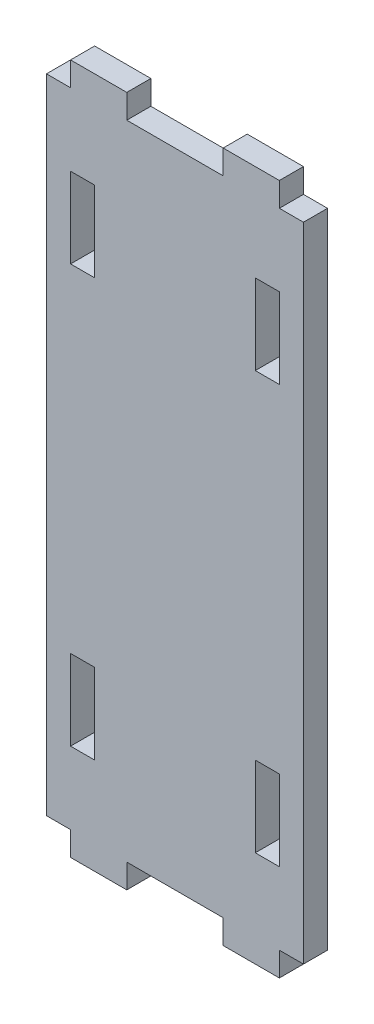
from build123d import *

# Parameters (mm, degrees)
SKETCH_1_W          = 32
SKETCH_1_H          = 86
EXTRUDE_1_DEPTH     = 3
SKETCH_2_W          = 12
SKETCH_2_H          = 3
SKETCH_2_W_2        = 3
CUT_EXTRUDE_1_DEPTH = 4
SKETCH_3_W          = 3
SKETCH_3_H          = 10
CUT_EXTRUDE_2_DEPTH = 4


with BuildPart() as part:
    # 스케치1 → 보스-돌출1 (new body)
    with BuildSketch(Plane.XY):
        with Locations((16, 43)):
            Rectangle(SKETCH_1_W, SKETCH_1_H)
    extrude(amount=EXTRUDE_1_DEPTH)

    # 스케치2 → 컷-돌출1 (cut, through all)
    with BuildSketch(Plane.XY.offset(3)):
        with Locations((16, 84.5)):
            Rectangle(SKETCH_2_W, SKETCH_2_H)
        with Locations((1.5, 84.5)):
            Rectangle(SKETCH_2_W_2, SKETCH_2_H)
        with Locations((30.5, 84.5)):
            Rectangle(SKETCH_2_W_2, SKETCH_2_H)
        with Locations((16, 1.5)):
            Rectangle(SKETCH_2_W, SKETCH_2_H)
        with Locations((1.5, 1.5)):
            Rectangle(SKETCH_2_W_2, SKETCH_2_H)
        with Locations((30.5, 1.5)):
            Rectangle(SKETCH_2_W_2, SKETCH_2_H)
    extrude(amount=-CUT_EXTRUDE_1_DEPTH, mode=Mode.SUBTRACT)

    # 스케치3 → 컷-돌출2 (cut, through all)
    with BuildSketch(Plane.XY.offset(3)):
        with Locations((27.5, 69)):
            Rectangle(SKETCH_3_W, SKETCH_3_H)
        with Locations((4.5, 69)):
            Rectangle(SKETCH_3_W, SKETCH_3_H)
        with Locations((27.5, 17)):
            Rectangle(SKETCH_3_W, SKETCH_3_H)
        with Locations((4.5, 17)):
            Rectangle(SKETCH_3_W, SKETCH_3_H)
    extrude(amount=-CUT_EXTRUDE_2_DEPTH, mode=Mode.SUBTRACT)


solid = part.part
